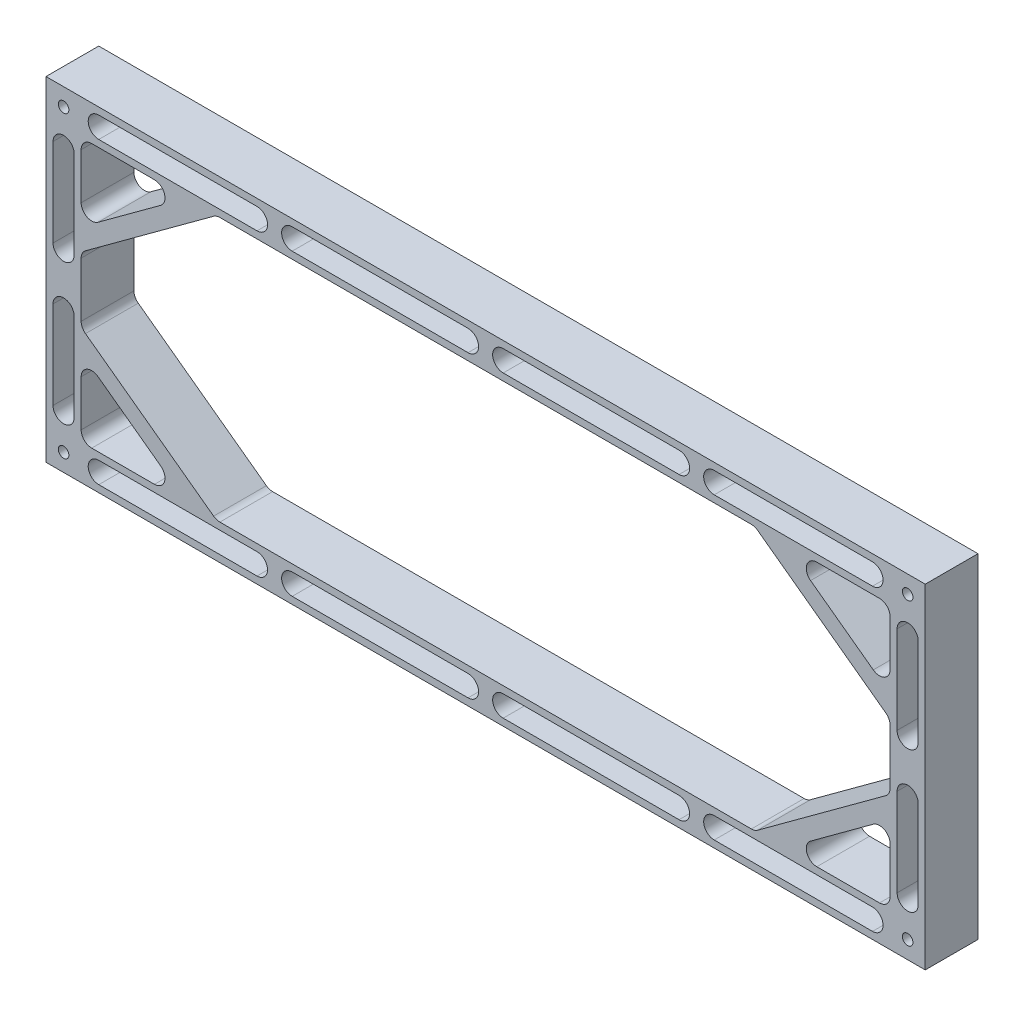
from build123d import *

# Parameters (mm, degrees)
SKETCH1_W                                      = 250
SKETCH1_H                                      = 95
SKETCH1_W_2                                    = 230
SKETCH1_H_2                                    = 75
BOSS_EXTRUDE1_DEPTH                            = 15
FILLET1_R                                      = 3
CUT_EXTRUDE2_DEPTH                             = 16
CBORE_FOR_M1_6_HEX_HEAD_CAP_SCREW1_D           = 3
CBORE_FOR_M1_6_HEX_HEAD_CAP_SCREW1_CBORE_D     = 5
CBORE_FOR_M1_6_HEX_HEAD_CAP_SCREW1_CBORE_DEPTH = 5


with BuildPart() as part:
    # Sketch1 → Boss-Extrude1 (new body)
    with BuildSketch(Plane.XY):
        with Locations((125, 47.5)):
            Rectangle(SKETCH1_W, SKETCH1_H)
        with Locations((125, 47.5)):
            Rectangle(SKETCH1_W_2, SKETCH1_H_2, mode=Mode.SUBTRACT)
        Polygon((40, 85), (10, 63), (10, 56.799641587), (48.455034199, 85), align=None)
        Polygon((48.455034199, 10), (10, 38.200358413), (10, 32), (40, 10), align=None)
        Polygon((240, 38.200358413), (201.544965801, 10), (210, 10), (240, 32), align=None)
        Polygon((210, 85), (201.544965801, 85), (240, 56.799641587), (240, 63), align=None)
    extrude(amount=BOSS_EXTRUDE1_DEPTH)

    # Fillet1
    fillet1_edges = [part.edges().sort_by_distance(p)[0] for p in [
        (10, 32, 7.5),
        (10, 10, 7.5),
        (40, 10, 7.5),
        (210, 10, 7.5),
        (240, 10, 7.5),
        (240, 32, 7.5),
        (240, 63, 7.5),
        (240, 85, 7.5),
        (210, 85, 7.5),
        (10, 85, 7.5),
        (10, 63, 7.5),
        (40, 85, 7.5),
        (48.455034199, 85, 7.5),
        (10, 56.799641587, 7.5),
        (10, 38.200358413, 7.5),
        (48.455034199, 10, 7.5),
        (201.544965801, 10, 7.5),
        (240, 38.200358413, 7.5),
        (240, 56.799641587, 7.5),
        (201.544965801, 85, 7.5),
    ]]
    fillet(fillet1_edges, radius=FILLET1_R)

    # Sketch11 → Cut-Extrude2 (cut, through all)
    with BuildSketch(Plane(origin=(0, 0, 0), x_dir=(-1, 0, 0), z_dir=(0, 0, -1))):
        with BuildLine():
            Line((-248, 80), (-248, 55))
            ThreePointArc((-248, 55), (-245, 52), (-242, 55))
            Line((-242, 55), (-242, 80))
            ThreePointArc((-242, 80), (-245, 83), (-248, 80))
        make_face()
        with BuildLine():
            Line((-248, 40), (-248, 15))
            ThreePointArc((-248, 15), (-245, 12), (-242, 15))
            Line((-242, 15), (-242, 40))
            ThreePointArc((-242, 40), (-245, 43), (-248, 40))
        make_face()
        with BuildLine():
            Line((-190, 8), (-235, 8))
            ThreePointArc((-235, 8), (-238, 5), (-235, 2))
            Line((-235, 2), (-190, 2))
            ThreePointArc((-190, 2), (-187, 5), (-190, 8))
        make_face()
        with BuildLine():
            Line((-130, 8), (-180, 8))
            ThreePointArc((-180, 8), (-183, 5), (-180, 2))
            Line((-180, 2), (-130, 2))
            ThreePointArc((-130, 2), (-127, 5), (-130, 8))
        make_face()
        with BuildLine():
            Line((-70, 8), (-120, 8))
            ThreePointArc((-120, 8), (-123, 5), (-120, 2))
            Line((-120, 2), (-70, 2))
            ThreePointArc((-70, 2), (-67, 5), (-70, 8))
        make_face()
        with BuildLine():
            Line((-15, 8), (-60, 8))
            ThreePointArc((-60, 8), (-63, 5), (-60, 2))
            Line((-60, 2), (-15, 2))
            ThreePointArc((-15, 2), (-12, 5), (-15, 8))
        make_face()
        with BuildLine():
            Line((-8, 40), (-8, 15))
            ThreePointArc((-8, 15), (-5, 12), (-2, 15))
            Line((-2, 15), (-2, 40))
            ThreePointArc((-2, 40), (-5, 43), (-8, 40))
        make_face()
        with BuildLine():
            Line((-8, 80), (-8, 55))
            ThreePointArc((-8, 55), (-5, 52), (-2, 55))
            Line((-2, 55), (-2, 80))
            ThreePointArc((-2, 80), (-5, 83), (-8, 80))
        make_face()
        with BuildLine():
            Line((-15, 93), (-60, 93))
            ThreePointArc((-60, 93), (-63, 90), (-60, 87))
            Line((-60, 87), (-15, 87))
            ThreePointArc((-15, 87), (-12, 90), (-15, 93))
        make_face()
        with BuildLine():
            Line((-70, 93), (-120, 93))
            ThreePointArc((-120, 93), (-123, 90), (-120, 87))
            Line((-120, 87), (-70, 87))
            ThreePointArc((-70, 87), (-67, 90), (-70, 93))
        make_face()
        with BuildLine():
            Line((-130, 93), (-180, 93))
            ThreePointArc((-180, 93), (-183, 90), (-180, 87))
            Line((-180, 87), (-130, 87))
            ThreePointArc((-130, 87), (-127, 90), (-130, 93))
        make_face()
        with BuildLine():
            Line((-190, 93), (-235, 93))
            ThreePointArc((-235, 93), (-238, 90), (-235, 87))
            Line((-235, 87), (-190, 87))
            ThreePointArc((-190, 87), (-187, 90), (-190, 93))
        make_face()
    extrude(amount=-CUT_EXTRUDE2_DEPTH, mode=Mode.SUBTRACT)

    # CBORE for M1.6 Hex Head Cap Screw1 (through all)
    with Locations(Plane(origin=(0, 0, 0), x_dir=(-1, 0, 0), z_dir=(0, 0, -1))):
        with Locations((-245, 90), (-245, 5), (-5, 5), (-5, 90)):
            CounterBoreHole(CBORE_FOR_M1_6_HEX_HEAD_CAP_SCREW1_D / 2, CBORE_FOR_M1_6_HEX_HEAD_CAP_SCREW1_CBORE_D / 2, CBORE_FOR_M1_6_HEX_HEAD_CAP_SCREW1_CBORE_DEPTH)


solid = part.part
